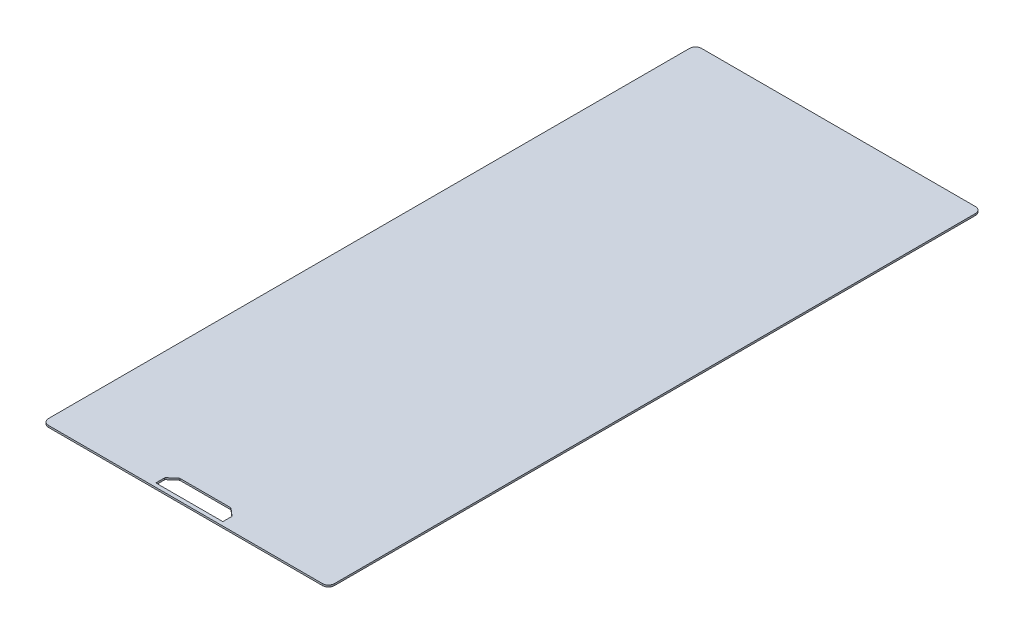
from build123d import *

# Parameters (mm, degrees)
BOSS_EXTRUDE1_DEPTH = 3
CUT_EXTRUDE1_DEPTH  = 4


with BuildPart() as part:
    # Sketch1 → Boss-Extrude1 (new body)
    with BuildSketch(Plane(origin=(0, 0, 0), x_dir=(1, 0, 0), z_dir=(0, 1, 0))):
        with BuildLine():
            Line((-231.5, -551.5), (231.5, -551.5))
            ThreePointArc((231.5, -551.5), (238.571067812, -548.571067812), (241.5, -541.5))
            Line((241.5, -541.5), (241.5, 541.5))
            ThreePointArc((241.5, 541.5), (238.571067812, 548.571067812), (231.5, 551.5))
            Line((231.5, 551.5), (-231.5, 551.5))
            ThreePointArc((-231.5, 551.5), (-238.571067812, 548.571067812), (-241.5, 541.5))
            Line((-241.5, 541.5), (-241.5, -541.5))
            ThreePointArc((-241.5, -541.5), (-238.571067812, -548.571067812), (-231.5, -551.5))
        make_face()
    extrude(amount=BOSS_EXTRUDE1_DEPTH)

    # Sketch2 → Cut-Extrude1 (cut, through all)
    with BuildSketch(Plane(origin=(0, 3, 0), x_dir=(1, 0, 0), z_dir=(0, 1, 0))):
        with BuildLine():
            Line((-56.625, -545), (56.625, -545))
            Line((56.625, -545), (56.625, -530.644630074))
            ThreePointArc((56.625, -530.644630074), (56.398076263, -529.603897494), (55.758500558, -528.752098455))
            Line((55.758500558, -528.752098455), (44.005193779, -518.607468381))
            ThreePointArc((44.005193779, -518.607468381), (43.243091796, -518.156783296), (42.371693222, -518))
            Line((42.371693222, -518), (-42.371693222, -518))
            ThreePointArc((-42.371693222, -518), (-43.243091796, -518.156783296), (-44.005193779, -518.607468381))
            Line((-44.005193779, -518.607468381), (-55.758500558, -528.752098455))
            ThreePointArc((-55.758500558, -528.752098455), (-56.398076263, -529.603897494), (-56.625, -530.644630074))
            Line((-56.625, -530.644630074), (-56.625, -545))
        make_face()
    extrude(amount=-CUT_EXTRUDE1_DEPTH, mode=Mode.SUBTRACT)


solid = part.part
